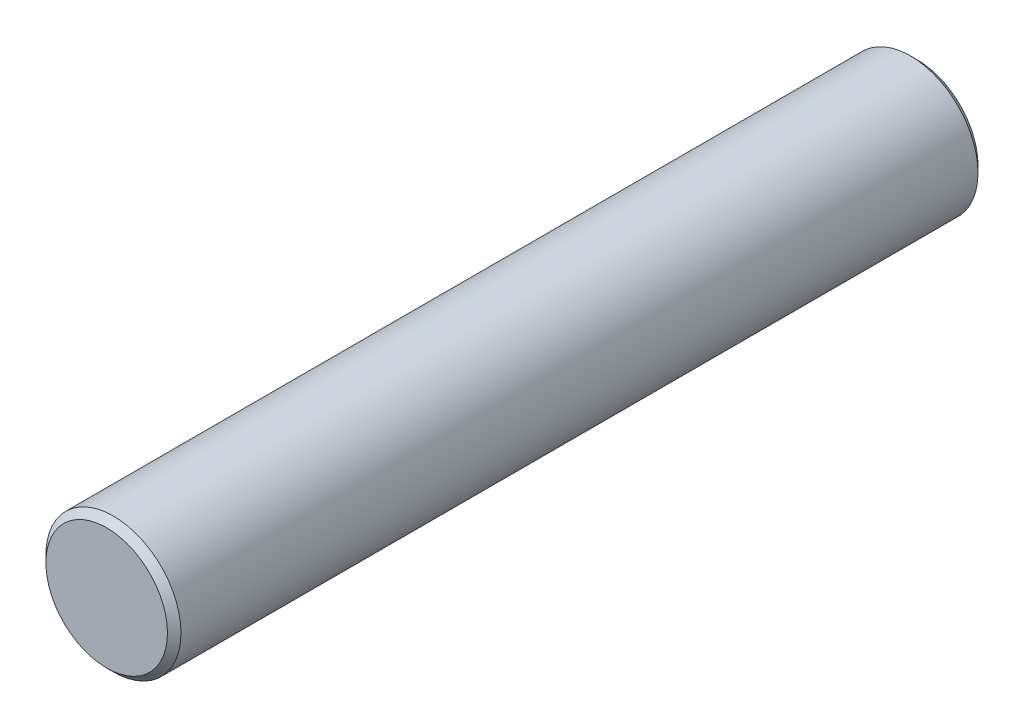
from build123d import *

# Parameters (mm, degrees)
SKETCH1_R           = 2.5
BOSS_EXTRUDE1_DEPTH = 30
CHAMFER1_SIZE       = 0.25


with BuildPart() as part:
    # Sketch1 → Boss-Extrude1 (new body)
    with BuildSketch(Plane.XY):
        Circle(SKETCH1_R)
    extrude(amount=BOSS_EXTRUDE1_DEPTH)

    # Chamfer1
    chamfer1_edges = [part.edges().sort_by_distance(p)[0] for p in [
        (-2.5, 0, 0),
        (-2.5, 0, 30),
    ]]
    chamfer(chamfer1_edges, length=CHAMFER1_SIZE)


solid = part.part
